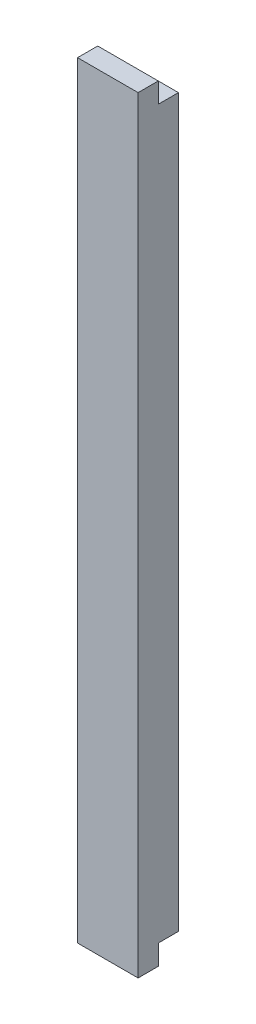
from build123d import *

# Parameters (mm, degrees)
SKETCH1_W           = 40
SKETCH1_H           = 380
BOSS_EXTRUDE1_DEPTH = 20
SKETCH2_W           = 10
SKETCH2_H           = 380
CUT_EXTRUDE1_DEPTH  = 10
SKETCH3_W           = 40
SKETCH3_H           = 10
CUT_EXTRUDE2_DEPTH  = 10


with BuildPart() as part:
    # Sketch1 → Boss-Extrude1 (new body)
    with BuildSketch(Plane.XY):
        Rectangle(SKETCH1_W, SKETCH1_H)
    extrude(amount=BOSS_EXTRUDE1_DEPTH)

    # Sketch2 → Cut-Extrude1 (cut)
    with BuildSketch(Plane.XY.offset(20)):
        with Locations((-15, 0)):
            Rectangle(SKETCH2_W, SKETCH2_H)
    extrude(amount=-CUT_EXTRUDE1_DEPTH, mode=Mode.SUBTRACT)

    # Sketch3 → Cut-Extrude2 (cut)
    with BuildSketch(Plane(origin=(0, 0, 0), x_dir=(-1, 0, 0), z_dir=(0, 0, -1))):
        with Locations((0, 185)):
            Rectangle(SKETCH3_W, SKETCH3_H)
        with Locations((0, -185)):
            Rectangle(SKETCH3_W, SKETCH3_H)
    extrude(amount=-CUT_EXTRUDE2_DEPTH, mode=Mode.SUBTRACT)


solid = part.part
